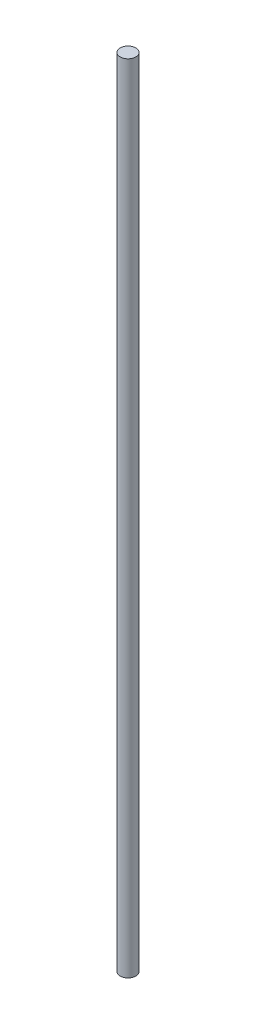
from build123d import *

# Parameters (mm, degrees)
SKETCH1_R           = 4
BOSS_EXTRUDE1_DEPTH = 406


with BuildPart() as part:
    # Sketch1 → Boss-Extrude1 (new body)
    with BuildSketch(Plane(origin=(0, 0, 0), x_dir=(1, 0, 0), z_dir=(0, 1, 0))):
        Circle(SKETCH1_R)
    extrude(amount=BOSS_EXTRUDE1_DEPTH)


solid = part.part
